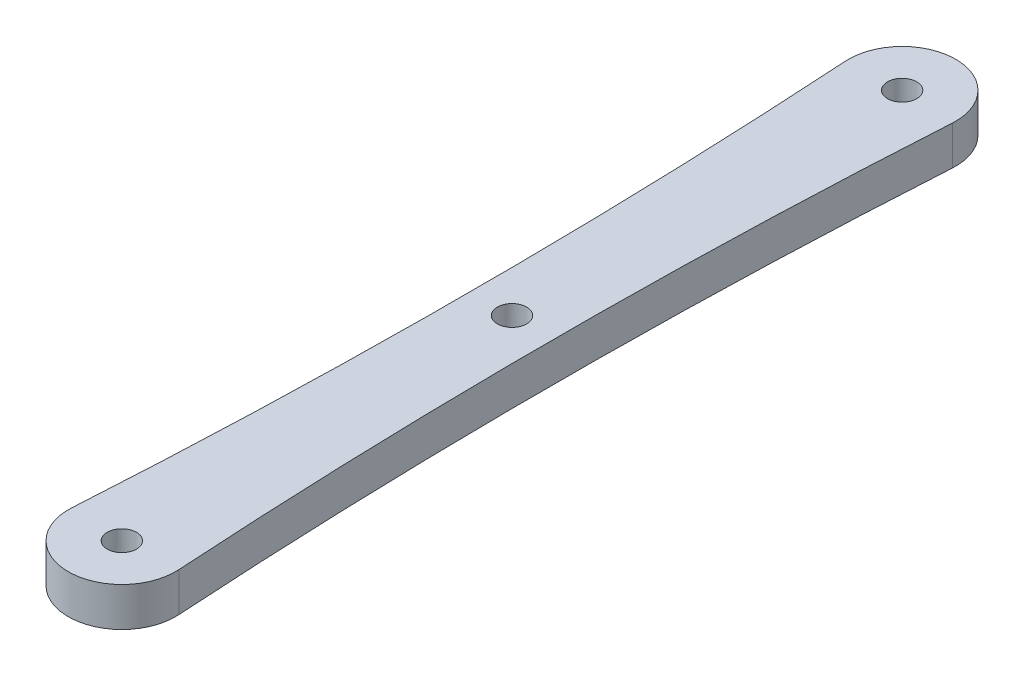
from build123d import *

# Parameters (mm, degrees)
SKETCH1_R           = 1.5
BOSS_EXTRUDE1_DEPTH = 4


with BuildPart() as part:
    # Sketch1 → Boss-Extrude1 (new body)
    with BuildSketch(Plane(origin=(0, 0, 0), x_dir=(1, 0, 0), z_dir=(0, 1, 0))):
        with BuildLine():
            ThreePointArc((-5.489268293, 0.343414634), (0, -5.5), (5.489268293, 0.343414634))
            ThreePointArc((5.489268293, 0.343414634), (4.25, 40), (5.489268293, 79.656585366))
            ThreePointArc((5.489268293, 79.656585366), (0, 85.5), (-5.489268293, 79.656585366))
            ThreePointArc((-5.489268293, 79.656585366), (-4.25, 40), (-5.489268293, 0.343414634))
        make_face()
        Circle(SKETCH1_R, mode=Mode.SUBTRACT)
        with Locations((0, 80)):
            Circle(SKETCH1_R, mode=Mode.SUBTRACT)
        with Locations((0, 40)):
            Circle(SKETCH1_R, mode=Mode.SUBTRACT)
    extrude(amount=BOSS_EXTRUDE1_DEPTH)


solid = part.part
